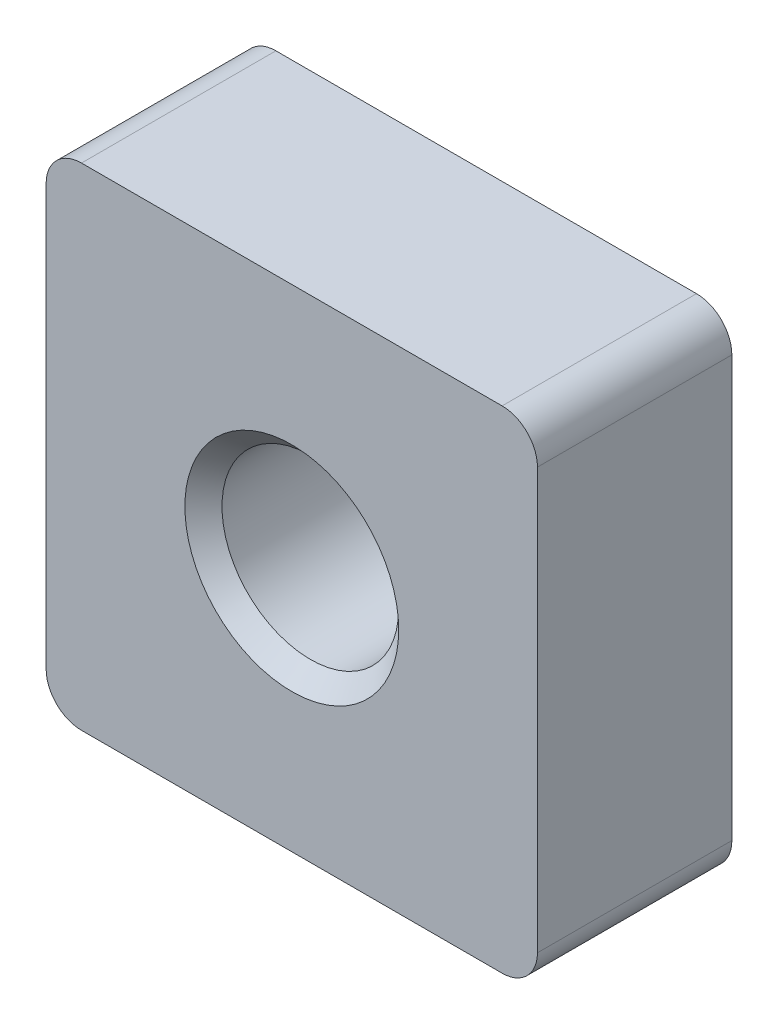
from build123d import *

# Parameters (mm, degrees)
SKETCH_1_W      = 13.9
SKETCH_1_H      = 13.9
EXTRUDE_1_DEPTH = 5.5
FILLET_1_R      = 1


with BuildPart() as part:
    # Эскиз1 → Бобышка-Вытянуть1 (new body)
    with BuildSketch(Plane.XY):
        Rectangle(SKETCH_1_W, SKETCH_1_H)
    extrude(amount=EXTRUDE_1_DEPTH)

    # Эскиз3 → Отверстие обработанное метчиком M61 (revolve, cut)
    with BuildSketch(Plane(origin=(0, 0, 5.5), x_dir=(0, -1, 0), z_dir=(1, 0, 0))):
        Polygon((0, 0), (0, 5.5), (3.025, 5.5), (2.5, 4.975), (2.5, 0.525), (3.025, 0), align=None)
    revolve(axis=Axis((0, 0, 11.85), (0, 0, -1)), mode=Mode.SUBTRACT)

    # Скругление1
    fillet_1_edges = [part.edges().sort_by_distance(p)[0] for p in [
        (6.95, -6.95, 2.75),
        (-6.95, -6.95, 2.75),
        (-6.95, 6.95, 2.75),
        (6.95, 6.95, 2.75),
    ]]
    fillet(fillet_1_edges, radius=FILLET_1_R)


solid = part.part
